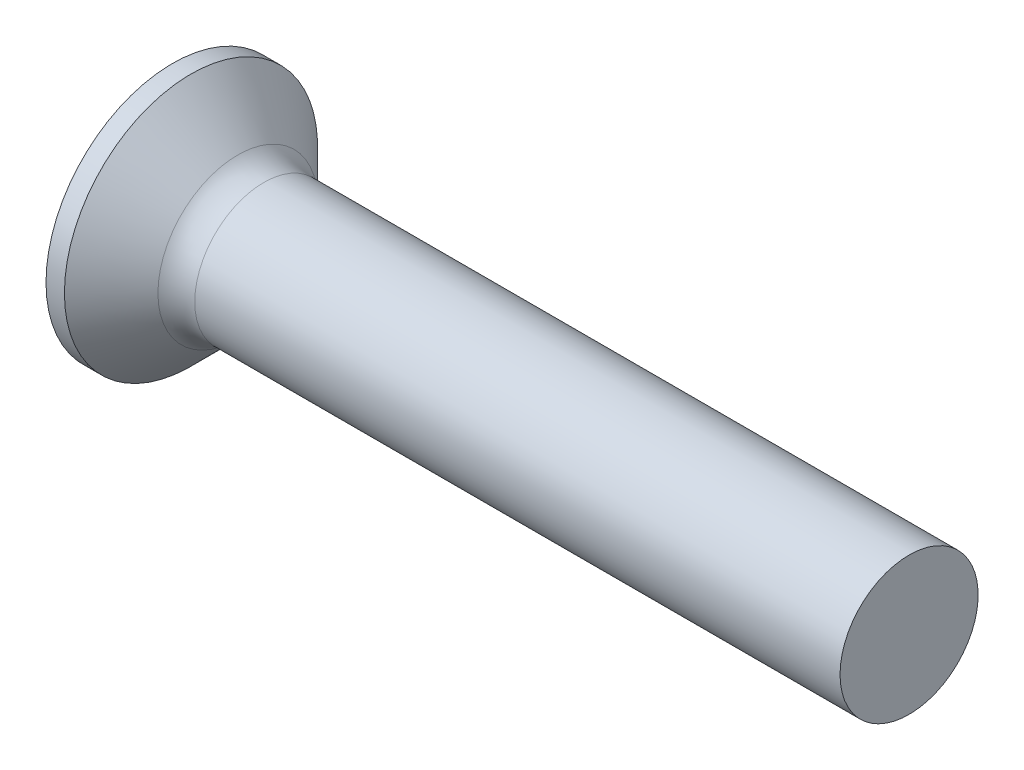
from build123d import *

# Parameters (mm, degrees)
FILLET1_R    = 0.8
SKETCH3_W    = 0.74
SKETCH3_H    = 3
SKETCH4_W    = 0.74
SKETCH4_H    = 0.99570227
RECPAT_COUNT = 2
RECPAT_ANGLE = 90


with BuildPart() as part:
    # BodySke → Base-Revolve (revolve)
    with BuildSketch(Plane.XY):
        Polygon((0, 0), (0, 2.75), (0.4, 2.75), (1.65, 1.5), (16, 1.5), (16, 0), align=None)
    revolve(axis=Axis((-6.35, 0, 0), (1, 0, 0)))

    # Fillet1
    fillet1_edges = [part.edges().sort_by_distance(p)[0] for p in [
        (1.65, -1.5, 0),
    ]]
    fillet(fillet1_edges, radius=FILLET1_R)

    # Sketch3 → Recess section 0
    with BuildSketch(Plane.ZY):
        Rectangle(SKETCH3_W, SKETCH3_H)
    # Sketch4 → Recess section 1
    with BuildSketch(Plane.ZY.offset(-2.01)):
        Rectangle(SKETCH4_W, SKETCH4_H)
    recess = loft(mode=Mode.SUBTRACT)

    # RecPat: Recess ×2 about axis
    recpat_axis = Axis((0, 0, 0), (1, 0, 0))
    for i in range(1, RECPAT_COUNT):
        add(recess.rotate(recpat_axis, i * RECPAT_ANGLE / (RECPAT_COUNT - 1)), mode=Mode.SUBTRACT)

    # RecCorSke → RecessCore (revolve, cut)
    with BuildSketch(Plane.XY):
        Polygon((0, 0), (0, 0.696552892), (2.01, 0.556), (2.190655351, 0), align=None)
    revolve(axis=Axis((-3.175, 0, 0), (1, 0, 0)), mode=Mode.SUBTRACT)


solid = part.part
